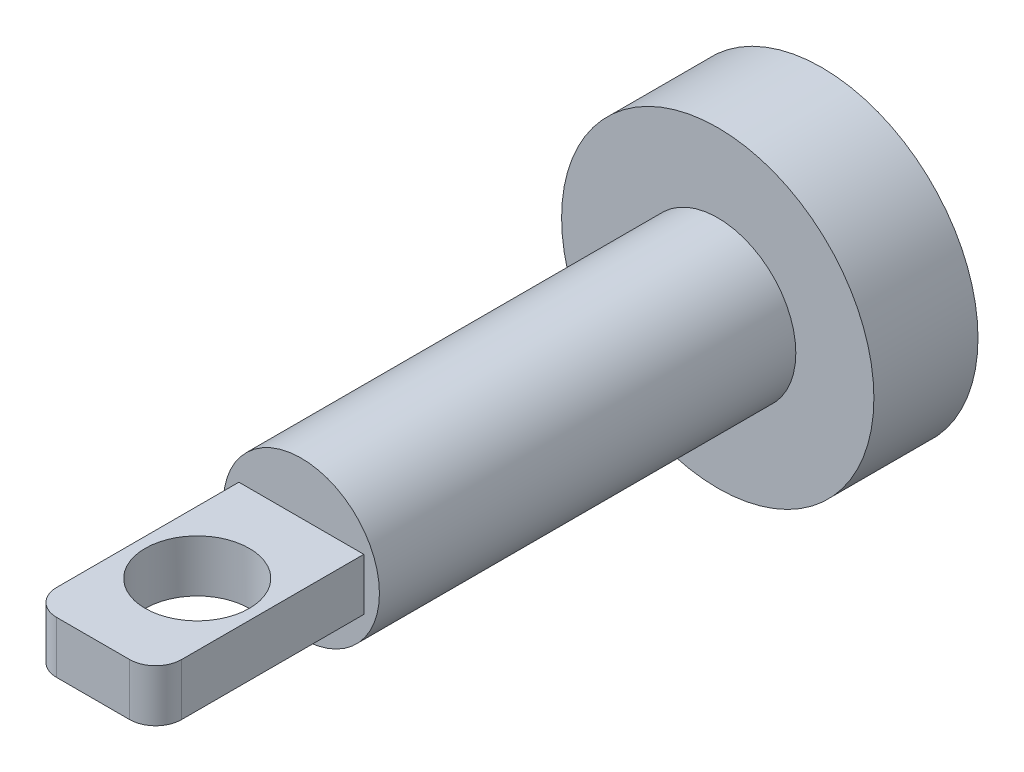
from build123d import *

# Parameters (mm, degrees)
SKETCH2_R               = 38.1
BOSS_EXTRUDE1_DEPTH     = 12.7
SKETCH3_R               = 19.05
BOSS_EXTRUDE2_DEPTH     = 101.6
SKETCH4_W               = 30.48
SKETCH4_H               = 12.7
BOSS_EXTRUDE3_DEPTH     = 50.8
FILLET1_R               = 6.35
SKETCH5_R               = 12.7
CUT_EXTRUDE1_DEPTH      = 32.75
CUT_EXTRUDE1_DEPTH_BACK = 45.45


with BuildPart() as part:
    # Sketch2 → Boss-Extrude1 (new body, symmetric)
    with BuildSketch(Plane.XY):
        Circle(SKETCH2_R)
    extrude(amount=BOSS_EXTRUDE1_DEPTH, both=True)

    # Sketch3 → Boss-Extrude2 (add)
    with BuildSketch(Plane.XY.offset(12.7)):
        Circle(SKETCH3_R)
    extrude(amount=BOSS_EXTRUDE2_DEPTH)

    # Sketch4 → Boss-Extrude3 (add)
    with BuildSketch(Plane.XY.offset(114.3)):
        Rectangle(SKETCH4_W, SKETCH4_H)
    extrude(amount=BOSS_EXTRUDE3_DEPTH)

    # Fillet1
    fillet1_edges = [part.edges().sort_by_distance(p)[0] for p in [
        (15.24, 0, 165.1),
        (-15.24, 0, 165.1),
    ]]
    fillet(fillet1_edges, radius=FILLET1_R)

    # Sketch5 → Cut-Extrude1 (cut, two sides)
    with BuildSketch(Plane(origin=(0, 6.35, 0), x_dir=(1, 0, 0), z_dir=(0, 1, 0))) as cut_extrude1_sk:
        with Locations((0, -139.7)):
            Circle(SKETCH5_R)
    extrude(amount=CUT_EXTRUDE1_DEPTH, mode=Mode.SUBTRACT)
    extrude(cut_extrude1_sk.sketch, amount=-CUT_EXTRUDE1_DEPTH_BACK, mode=Mode.SUBTRACT)


solid = part.part
